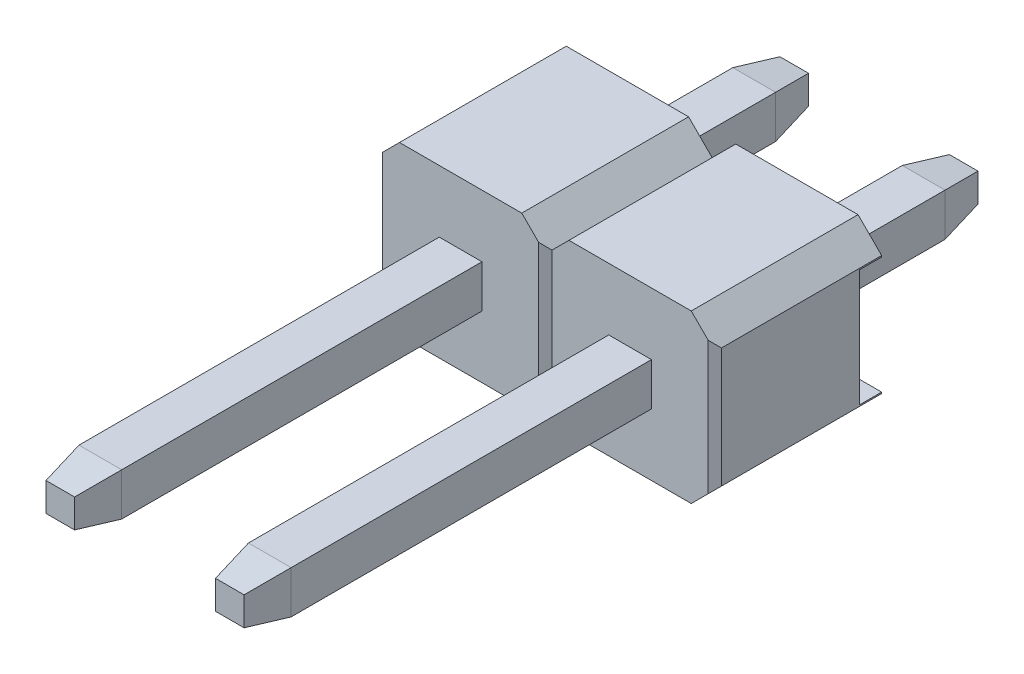
from build123d import *
from OCP.BRepFilletAPI import BRepFilletAPI_MakeChamfer

# Parameters (mm, degrees)
EXTRUDE1_DEPTH          = 1.25
CUT_EXTRUDE3_DEPTH      = 3.176671771
LPATTERN4_COUNT         = 2
LPATTERN4_PITCH         = 2.54
CUT_EXTRUDE1_DEPTH      = 5.20013095
CUT_EXTRUDE1_DEPTH_BACK = 5.20013095
SKETCH2_W               = 1.752893218
SKETCH2_H               = 0.33
SKETCH3_W               = 11
SKETCH3_H               = 0.64
EXTRUDE_THIN1_DEPTH     = 0.32
LPATTERN5_COUNT         = 2
LPATTERN5_PITCH         = 2.54
CHAMFER2_SIZE           = 0.6
CHAMFER2_SIZE2          = 0.105796188


with BuildPart() as part:
    # Sketch1 → Extrude1 (new, symmetric)
    with BuildSketch(Plane.XY):
        Polygon((-1.27, 0.896446609), (-0.916446609, 1.25), (0.916446609, 1.25), (1.27, 0.896446609), (1.27, -0.896446609), (0.916446609, -1.25), (-0.916446609, -1.25), (-1.27, -0.896446609), align=None)
    extrude1 = extrude(amount=EXTRUDE1_DEPTH, both=True)

    # Sketch4 → Cut-Extrude3 (cut, symmetric)
    with BuildSketch(Plane(origin=(0, 0, 0), x_dir=(1, 0, 0), z_dir=(0, 1, 0))):
        Polygon((-1.27, -1.15), (-1.17, -1.25), (-1.27, -1.25), align=None)
        Polygon((1.17, -1.25), (1.27, -1.15), (1.27, -1.25), align=None)
    cut_extrude3 = extrude(amount=CUT_EXTRUDE3_DEPTH, both=True, mode=Mode.SUBTRACT)

    # LPattern4: Extrude1, Cut-Extrude3 ×2
    with Locations(*[(-i * LPATTERN4_PITCH, 0, 0) for i in range(1, LPATTERN4_COUNT)]):
        add(extrude1)
        add(cut_extrude3, mode=Mode.SUBTRACT)

    # Sketch2 → Cut-Extrude1 (cut, two sides: drawn at the far end of the back side and taken through both)
    with BuildSketch(Plane(origin=(0, 0, 0), x_dir=(0, -1, 0), z_dir=(1, 0, 0)).offset(-CUT_EXTRUDE1_DEPTH_BACK)):
        with Locations((0, 1.085)):
            Rectangle(SKETCH2_W, SKETCH2_H)
    extrude(amount=CUT_EXTRUDE1_DEPTH + CUT_EXTRUDE1_DEPTH_BACK, mode=Mode.SUBTRACT)

    # Sketch3 → Extrude-Thin1 (add, symmetric)
    with BuildSketch(Plane(origin=(0, 0, 0), x_dir=(0, 0, -1), z_dir=(1, 0, 0))):
        with Locations((-1.75, 0)):
            Rectangle(SKETCH3_W, SKETCH3_H)
    extrude_thin1 = extrude(amount=EXTRUDE_THIN1_DEPTH, both=True)

    # LPattern5: Extrude-Thin1 ×2
    with Locations(*[(-i * LPATTERN5_PITCH, 0, 0) for i in range(1, LPATTERN5_COUNT)]):
        add(extrude_thin1)

    # Chamfer2: one chamfer whose edges measure the first distance from different faces: ONE call of the kernel's chamfer builder (chamfer() names one face for all edges)
    chamfer2_edges_1 = [part.edges().sort_by_distance(p)[0] for p in [
        (0.32, 0, 7.25),
    ]]
    chamfer2_side_1 = [part.faces().sort_by_distance(p)[0] for p in [
        (0.32, 0, 4.25),
    ]]
    chamfer2_edges_2 = [part.edges().sort_by_distance(p)[0] for p in [
        (0, -0.32, 7.25),
    ]]
    chamfer2_side_2 = [part.faces().sort_by_distance(p)[0] for p in [
        (0, -0.32, 4.25),
    ]]
    chamfer2_edges_3 = [part.edges().sort_by_distance(p)[0] for p in [
        (-0.32, 0, 7.25),
    ]]
    chamfer2_side_3 = [part.faces().sort_by_distance(p)[0] for p in [
        (-0.32, 0, 4.25),
    ]]
    chamfer2_edges_4 = [part.edges().sort_by_distance(p)[0] for p in [
        (0, 0.32, 7.25),
    ]]
    chamfer2_side_4 = [part.faces().sort_by_distance(p)[0] for p in [
        (0, 0.32, 4.25),
    ]]
    chamfer2_edges_5 = [part.edges().sort_by_distance(p)[0] for p in [
        (0.32, 0, -3.75),
    ]]
    chamfer2_side_5 = [part.faces().sort_by_distance(p)[0] for p in [
        (0.32, 0, -2.335),
    ]]
    chamfer2_edges_6 = [part.edges().sort_by_distance(p)[0] for p in [
        (-0.32, 0, -3.75),
    ]]
    chamfer2_side_6 = [part.faces().sort_by_distance(p)[0] for p in [
        (-0.32, 0, -2.335),
    ]]
    chamfer2_edges_7 = [part.edges().sort_by_distance(p)[0] for p in [
        (-2.22, 0, -3.75),
    ]]
    chamfer2_side_7 = [part.faces().sort_by_distance(p)[0] for p in [
        (-2.22, 0, -2.335),
    ]]
    chamfer2_edges_8 = [part.edges().sort_by_distance(p)[0] for p in [
        (-2.86, 0, -3.75),
    ]]
    chamfer2_side_8 = [part.faces().sort_by_distance(p)[0] for p in [
        (-2.86, 0, -2.335),
    ]]
    chamfer2_edges_9 = [part.edges().sort_by_distance(p)[0] for p in [
        (-2.22, 0, 7.25),
    ]]
    chamfer2_side_9 = [part.faces().sort_by_distance(p)[0] for p in [
        (-2.22, 0, 4.25),
    ]]
    chamfer2_edges_10 = [part.edges().sort_by_distance(p)[0] for p in [
        (-2.54, -0.32, 7.25),
    ]]
    chamfer2_side_10 = [part.faces().sort_by_distance(p)[0] for p in [
        (-2.54, -0.32, 4.25),
    ]]
    chamfer2_edges_11 = [part.edges().sort_by_distance(p)[0] for p in [
        (-2.86, 0, 7.25),
    ]]
    chamfer2_side_11 = [part.faces().sort_by_distance(p)[0] for p in [
        (-2.86, 0, 4.25),
    ]]
    chamfer2_edges_12 = [part.edges().sort_by_distance(p)[0] for p in [
        (-2.54, 0.32, 7.25),
    ]]
    chamfer2_side_12 = [part.faces().sort_by_distance(p)[0] for p in [
        (-2.54, 0.32, 4.25),
    ]]
    chamfer2_edges_13 = [part.edges().sort_by_distance(p)[0] for p in [
        (-2.54, 0.32, -3.75),
    ]]
    chamfer2_side_13 = [part.faces().sort_by_distance(p)[0] for p in [
        (-2.54, 0.32, -2.335),
    ]]
    chamfer2_edges_14 = [part.edges().sort_by_distance(p)[0] for p in [
        (-2.54, -0.32, -3.75),
    ]]
    chamfer2_side_14 = [part.faces().sort_by_distance(p)[0] for p in [
        (-2.54, -0.32, -2.335),
    ]]
    chamfer2_edges_15 = [part.edges().sort_by_distance(p)[0] for p in [
        (0, 0.32, -3.75),
    ]]
    chamfer2_side_15 = [part.faces().sort_by_distance(p)[0] for p in [
        (0, 0.32, -2.335),
    ]]
    chamfer2_edges_16 = [part.edges().sort_by_distance(p)[0] for p in [
        (0, -0.32, -3.75),
    ]]
    chamfer2_side_16 = [part.faces().sort_by_distance(p)[0] for p in [
        (0, -0.32, -2.335),
    ]]
    chamfer2 = BRepFilletAPI_MakeChamfer(part.part.solid().wrapped)
    for e in chamfer2_edges_1:
        chamfer2.Add(CHAMFER2_SIZE, CHAMFER2_SIZE2, e.wrapped, chamfer2_side_1[0].wrapped)  # the first distance lies on this face
    for e in chamfer2_edges_2:
        chamfer2.Add(CHAMFER2_SIZE, CHAMFER2_SIZE2, e.wrapped, chamfer2_side_2[0].wrapped)  # the first distance lies on this face
    for e in chamfer2_edges_3:
        chamfer2.Add(CHAMFER2_SIZE, CHAMFER2_SIZE2, e.wrapped, chamfer2_side_3[0].wrapped)  # the first distance lies on this face
    for e in chamfer2_edges_4:
        chamfer2.Add(CHAMFER2_SIZE, CHAMFER2_SIZE2, e.wrapped, chamfer2_side_4[0].wrapped)  # the first distance lies on this face
    for e in chamfer2_edges_5:
        chamfer2.Add(CHAMFER2_SIZE, CHAMFER2_SIZE2, e.wrapped, chamfer2_side_5[0].wrapped)  # the first distance lies on this face
    for e in chamfer2_edges_6:
        chamfer2.Add(CHAMFER2_SIZE, CHAMFER2_SIZE2, e.wrapped, chamfer2_side_6[0].wrapped)  # the first distance lies on this face
    for e in chamfer2_edges_7:
        chamfer2.Add(CHAMFER2_SIZE, CHAMFER2_SIZE2, e.wrapped, chamfer2_side_7[0].wrapped)  # the first distance lies on this face
    for e in chamfer2_edges_8:
        chamfer2.Add(CHAMFER2_SIZE, CHAMFER2_SIZE2, e.wrapped, chamfer2_side_8[0].wrapped)  # the first distance lies on this face
    for e in chamfer2_edges_9:
        chamfer2.Add(CHAMFER2_SIZE, CHAMFER2_SIZE2, e.wrapped, chamfer2_side_9[0].wrapped)  # the first distance lies on this face
    for e in chamfer2_edges_10:
        chamfer2.Add(CHAMFER2_SIZE, CHAMFER2_SIZE2, e.wrapped, chamfer2_side_10[0].wrapped)  # the first distance lies on this face
    for e in chamfer2_edges_11:
        chamfer2.Add(CHAMFER2_SIZE, CHAMFER2_SIZE2, e.wrapped, chamfer2_side_11[0].wrapped)  # the first distance lies on this face
    for e in chamfer2_edges_12:
        chamfer2.Add(CHAMFER2_SIZE, CHAMFER2_SIZE2, e.wrapped, chamfer2_side_12[0].wrapped)  # the first distance lies on this face
    for e in chamfer2_edges_13:
        chamfer2.Add(CHAMFER2_SIZE, CHAMFER2_SIZE2, e.wrapped, chamfer2_side_13[0].wrapped)  # the first distance lies on this face
    for e in chamfer2_edges_14:
        chamfer2.Add(CHAMFER2_SIZE, CHAMFER2_SIZE2, e.wrapped, chamfer2_side_14[0].wrapped)  # the first distance lies on this face
    for e in chamfer2_edges_15:
        chamfer2.Add(CHAMFER2_SIZE, CHAMFER2_SIZE2, e.wrapped, chamfer2_side_15[0].wrapped)  # the first distance lies on this face
    for e in chamfer2_edges_16:
        chamfer2.Add(CHAMFER2_SIZE, CHAMFER2_SIZE2, e.wrapped, chamfer2_side_16[0].wrapped)  # the first distance lies on this face
    add(Compound.cast(chamfer2.Shape()), mode=Mode.REPLACE)


solid = part.part
